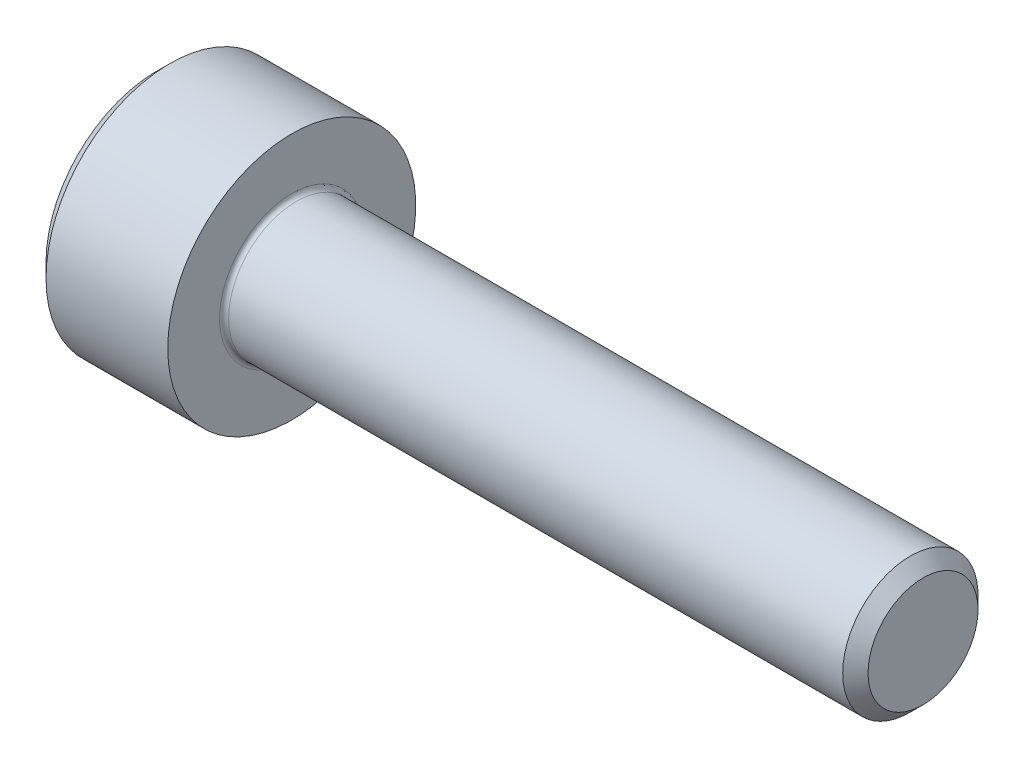
from build123d import *

# Parameters (mm, degrees)
FILLET1_R   = 0.1
HEX_2_DEPTH = 1.3


with BuildPart() as part:
    # BodySke → Base-Revolve (revolve)
    with BuildSketch(Plane.XY):
        Polygon((0, 0), (0, 2.45), (0.3, 2.75), (3, 2.75), (3, 1.5), (16.7195, 1.5), (17, 1.2195), (17, 0), align=None)
    revolve(axis=Axis((-31.75, 0, 0), (1, 0, 0)))

    # Fillet1
    fillet1_edges = [part.edges().sort_by_distance(p)[0] for p in [
        (3, -1.5, 0),
    ]]
    fillet(fillet1_edges, radius=FILLET1_R)

    # Sketch2 → Hex-PreBroach (revolve, cut)
    with BuildSketch(Plane.XY):
        Polygon((0, 1.28), (1.3, 1.28), (2.039008345, 0), (0, 0), align=None)
    revolve(axis=Axis((0, 0, 0), (1, 0, 0)), mode=Mode.SUBTRACT)

    # Sketch3 → Hex 2 (cut)
    with BuildSketch(Plane(origin=(0, 0, 0), x_dir=(0, 0.5, 0.866025404), z_dir=(-1, 0, 0))):
        Polygon((0.739008345, 1.28), (-0.739008345, 1.28), (-1.478016689, 0), (-0.739008345, -1.28), (0.739008345, -1.28), (1.478016689, 0), align=None)
    extrude(amount=-HEX_2_DEPTH, mode=Mode.SUBTRACT)


solid = part.part
